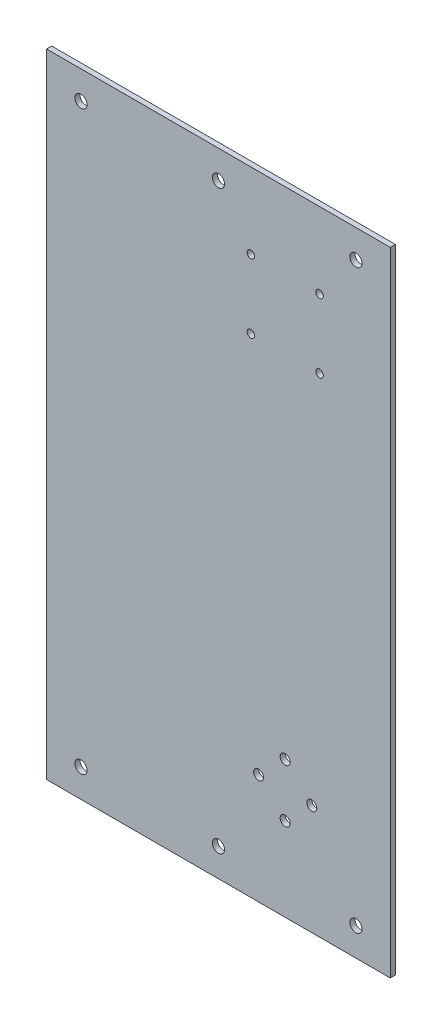
from build123d import *

# Parameters (mm, degrees)
SKETCH1_W            = 155
SKETCH1_H            = 285.39
BOSS_EXTRUDE1_DEPTH  = 2.305
M5_CLEARANCE_HOLE1_D = 5.5
SKETCH4_R            = 2.25
SKETCH4_R_2          = 1.7
CUT_EXTRUDE1_DEPTH   = 3.305


with BuildPart() as part:
    # Sketch1 → Boss-Extrude1 (new body)
    with BuildSketch(Plane.XY):
        Rectangle(SKETCH1_W, SKETCH1_H)
    extrude(amount=BOSS_EXTRUDE1_DEPTH)

    # M5 Clearance Hole1 (through all)
    with Locations(Plane.XY.offset(2.305)):
        with Locations((-62, 129.995), (0, 129.995), (-62, -129.995), (0, -129.995), (62, -129.995)):
            m5_clearance_hole1 = Hole(M5_CLEARANCE_HOLE1_D / 2)

    # Sketch4 → Cut-Extrude1 (cut, through all)
    with BuildSketch(Plane.XY.offset(2.305)):
        with Locations((30.1, -81)):
            Circle(SKETCH4_R)
        with Locations((42.1, -93)):
            Circle(SKETCH4_R)
        with Locations((30.1, -105)):
            Circle(SKETCH4_R)
        with Locations((18.1, -93)):
            Circle(SKETCH4_R)
        with Locations((45.6, 108.5)):
            Circle(SKETCH4_R_2)
        with Locations((14.6, 77.5)):
            Circle(SKETCH4_R_2)
        with Locations((45.6, 77.5)):
            Circle(SKETCH4_R_2)
        with Locations((14.6, 108.5)):
            Circle(SKETCH4_R_2)
    extrude(amount=-CUT_EXTRUDE1_DEPTH, mode=Mode.SUBTRACT)

    # Mirror1: M5 Clearance Hole1 across plane
    add(m5_clearance_hole1.mirror(Plane.ZX), mode=Mode.SUBTRACT)


solid = part.part
